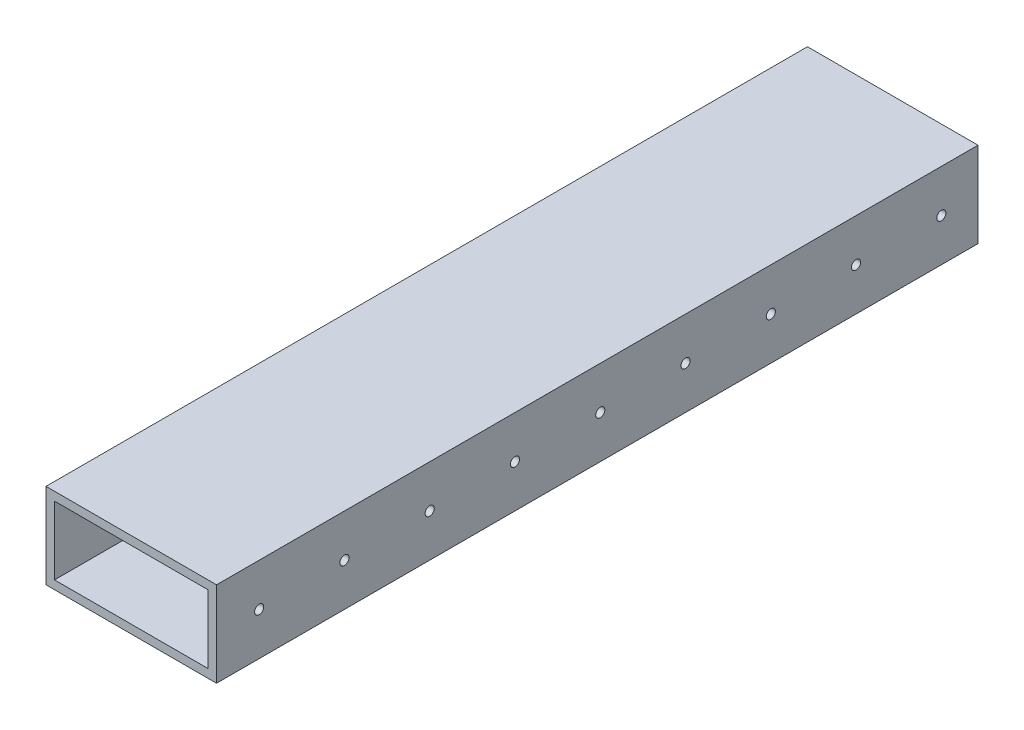
from build123d import *

# Parameters (mm, degrees)
SKETCH1_W           = 50.8
SKETCH1_H           = 25.4
SKETCH1_W_2         = 45.72
SKETCH1_H_2         = 20.32
EXTRUDE_THIN1_DEPTH = 113.411
SKETCH2_R           = 1.3589
CUT_EXTRUDE1_DEPTH  = 51.8
LPATTERN1_COUNT     = 9
LPATTERN1_PITCH     = 25.4


with BuildPart() as part:
    # Sketch1 → Extrude-Thin1 (new body, symmetric)
    with BuildSketch(Plane.XY):
        Rectangle(SKETCH1_W, SKETCH1_H)
        Rectangle(SKETCH1_W_2, SKETCH1_H_2, mode=Mode.SUBTRACT)
    extrude(amount=EXTRUDE_THIN1_DEPTH, both=True)

    # Sketch2 → Cut-Extrude1 (cut, through all)
    with BuildSketch(Plane(origin=(25.4, 0, 0), x_dir=(0, 0, -1), z_dir=(1, 0, 0))):
        with Locations((-100.711, 0)):
            Circle(SKETCH2_R)
    cut_extrude1 = extrude(amount=-CUT_EXTRUDE1_DEPTH, mode=Mode.SUBTRACT)

    # LPattern1: Cut-Extrude1 ×9
    with Locations(*[(0, 0, -i * LPATTERN1_PITCH) for i in range(1, LPATTERN1_COUNT)]):
        add(cut_extrude1, mode=Mode.SUBTRACT)


solid = part.part
